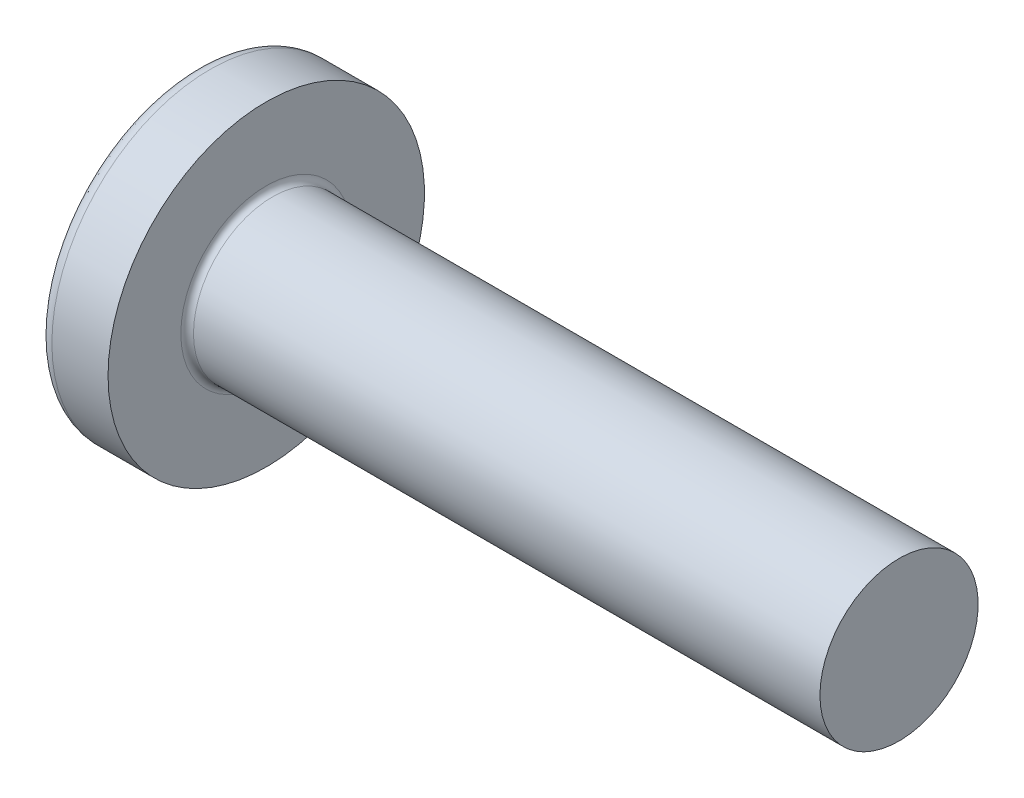
from build123d import *

# Parameters (mm, degrees)
FILLET1_R    = 0.4
SKETCH3_W    = 2.16
SKETCH3_H    = 9.9
SKETCH4_W    = 2.16
SKETCH4_H    = 4.226141496
RECPAT_COUNT = 2
RECPAT_ANGLE = 90


with BuildPart() as part:
    # BodySke → Base-Revolve (revolve)
    with BuildSketch(Plane.XY):
        with BuildLine():
            Line((7.5, 5), (7.5, 10))
            Line((7.5, 10), (3.950103735, 10))
            ThreePointArc((3.950103735, 10), (3.548946469, 9.905650574), (3.231897997, 9.642384106))
            ThreePointArc((3.231897997, 9.642384106), (0.82947542, 5.084799306), (0, 0))
            Line((0, 0), (47.5, 0))
            Line((47.5, 0), (47.5, 5))
            Line((47.5, 5), (7.5, 5))
        make_face()
    revolve(axis=Axis((-25.4, 0, 0), (1, 0, 0)))

    # Fillet1
    fillet1_edges = [part.edges().sort_by_distance(p)[0] for p in [
        (7.5, -5, 0),
    ]]
    fillet(fillet1_edges, radius=FILLET1_R)

    # Sketch3 → Recess section 0
    with BuildSketch(Plane(origin=(0, 0, 0), x_dir=(0, 0, -1), z_dir=(1, 0, 0))):
        Rectangle(SKETCH3_W, SKETCH3_H)
    # Sketch4 → Recess section 1
    with BuildSketch(Plane(origin=(5.69, 0, 0), x_dir=(0, 0, -1), z_dir=(1, 0, 0))):
        Rectangle(SKETCH4_W, SKETCH4_H)
    recess = loft(mode=Mode.SUBTRACT)

    # RecPat: Recess ×2 about axis
    recpat_axis = Axis((0, 0, 0), (1, 0, 0))
    for i in range(1, RECPAT_COUNT):
        add(recess.rotate(recpat_axis, i * RECPAT_ANGLE / (RECPAT_COUNT - 1)), mode=Mode.SUBTRACT)

    # RecCorSke → RecessCore (revolve, cut)
    with BuildSketch(Plane.XY):
        Polygon((0, 0), (0, 2.32838356), (5.69, 1.9305), (6.317257474, 0), align=None)
    revolve(axis=Axis((-3.175, 0, 0), (1, 0, 0)), mode=Mode.SUBTRACT)


solid = part.part
